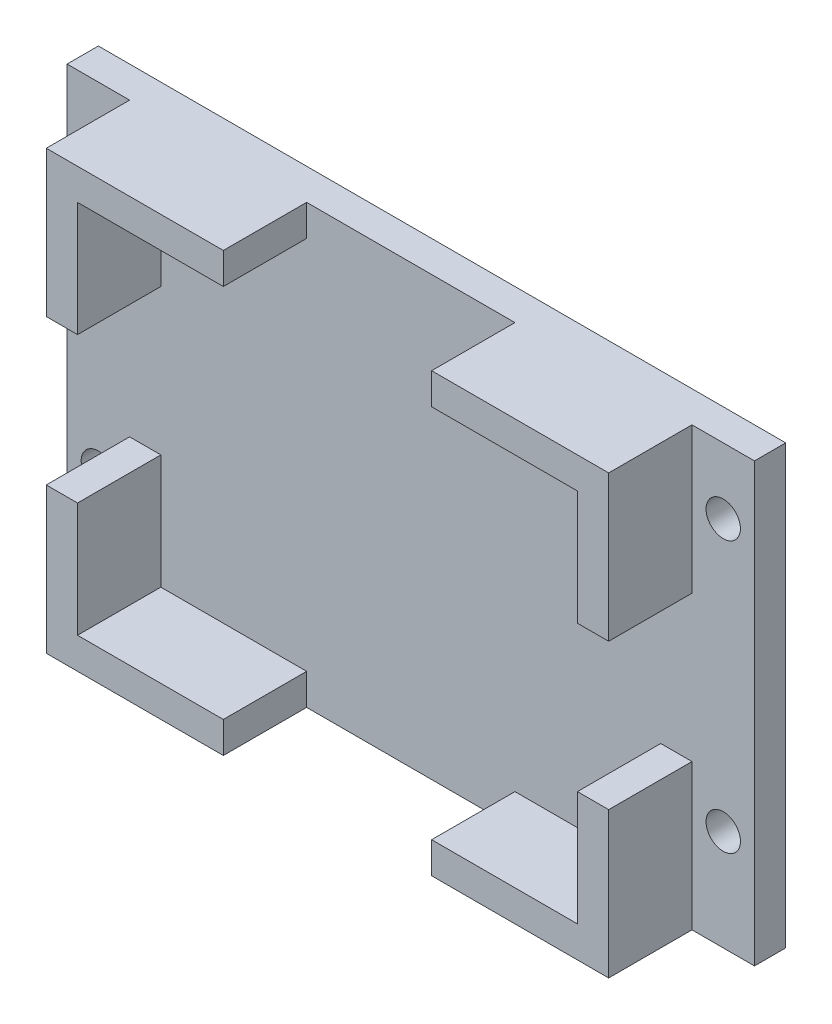
from build123d import *

# Parameters (mm, degrees)
SKETCH_1_R               = 1.65
EXTRUDE_3_DEPTH          = 3
SKETCH_3_W               = 54
SKETCH_3_H               = 42
SKETCH_3_W_2             = 48
SKETCH_3_H_2             = 36
EXTRUDE_4_DEPTH          = 8
CUT_EXTRUDE_1_DEPTH      = 1
CUT_EXTRUDE_1_DEPTH_BACK = 43
SKETCH_5_W               = 8
SKETCH_5_H               = 14
CUT_EXTRUDE_2_DEPTH      = 61


with BuildPart() as part:
    # 草图1 → 凸台-拉伸3 (new body)
    with BuildSketch(Plane.XY):
        Polygon((0, 21), (-30, 21), (-33, 21), (-33, -21), (33, -21), (33, 21), align=None)
        with Locations((-30, -11.316768896)):
            Circle(SKETCH_1_R, mode=Mode.SUBTRACT)
        with BuildLine():
            ThreePointArc((-30, 13.033231104), (-31.65, 14.683231104), (-30, 16.333231104))
            ThreePointArc((-30, 16.333231104), (-28.35, 14.683231104), (-30, 13.033231104))
        make_face(mode=Mode.SUBTRACT)
        with Locations((30, 14.683231104)):
            Circle(SKETCH_1_R, mode=Mode.SUBTRACT)
        with Locations((30, -11.316768896)):
            Circle(SKETCH_1_R, mode=Mode.SUBTRACT)
    extrude(amount=EXTRUDE_3_DEPTH)

    # 草图3 → 凸台-拉伸4 (add)
    with BuildSketch(Plane.XY.offset(3)):
        Rectangle(SKETCH_3_W, SKETCH_3_H)
        Rectangle(SKETCH_3_W_2, SKETCH_3_H_2, mode=Mode.SUBTRACT)
    extrude(amount=EXTRUDE_4_DEPTH)

    # 草图4 → 切除-拉伸1 (cut, two sides)
    with BuildSketch(Plane.XZ.offset(21)) as cut_extrude_1_sk:
        Polygon((-10, 109.769364085), (-10, 11), (-10, 3), (10, 3), (10, 11), (10, 109.769364085), (10, 307.308092254), (-10, 307.308092254), align=None)
    extrude(amount=CUT_EXTRUDE_1_DEPTH, mode=Mode.SUBTRACT)
    extrude(cut_extrude_1_sk.sketch, amount=-CUT_EXTRUDE_1_DEPTH_BACK, mode=Mode.SUBTRACT)

    # 草图5 → 切除-拉伸2 (cut, through all)
    with BuildSketch(Plane.ZY.offset(27)):
        with Locations((7, 0)):
            Rectangle(SKETCH_5_W, SKETCH_5_H)
    extrude(amount=-CUT_EXTRUDE_2_DEPTH, mode=Mode.SUBTRACT)


solid = part.part
